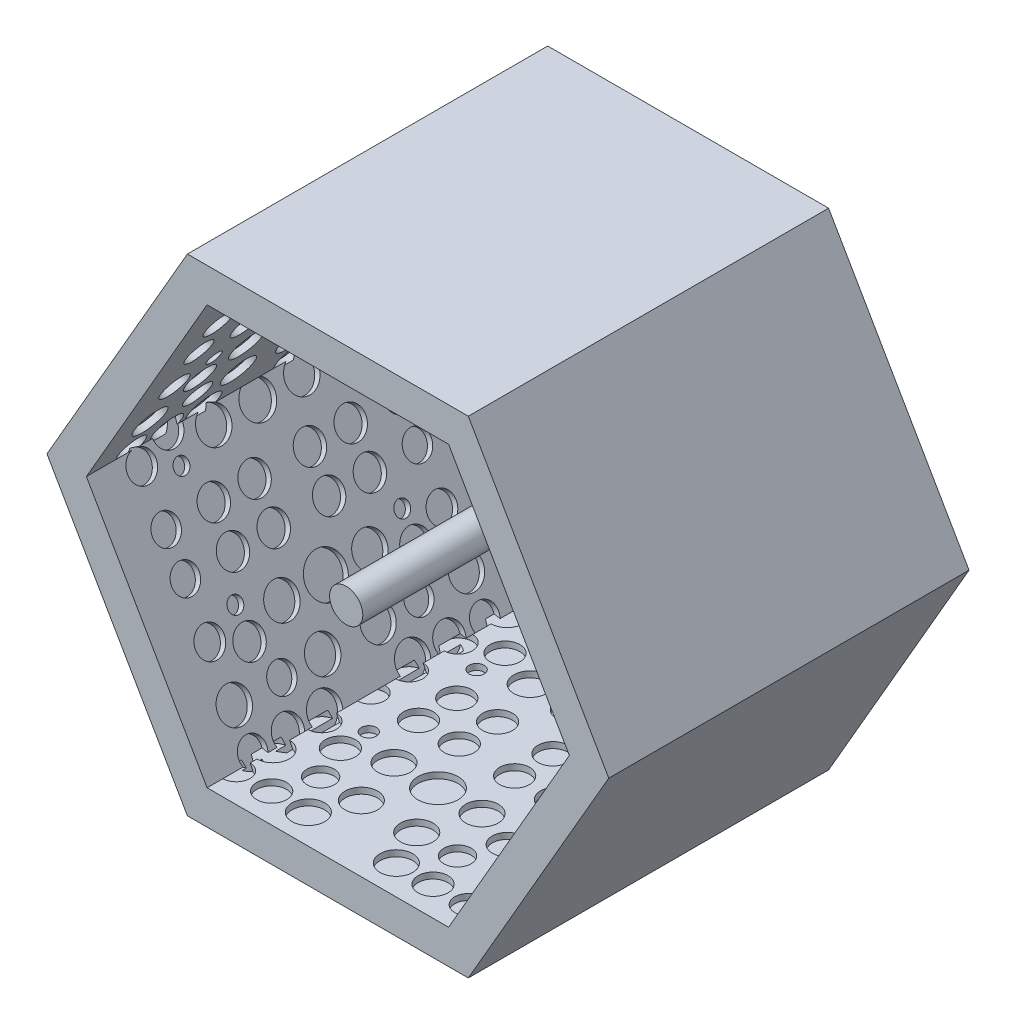
from build123d import *

# Parameters (mm, degrees)
SALIENTE_EXTRUIR2_DEPTH = 80
SALIENTE_EXTRUIR5_DEPTH = 510
CROQUIS4_R              = 151.648369314
SALIENTE_EXTRUIR6_DEPTH = 10
CROQUIS5_R              = 22.372806582
CROQUIS5_R_2            = 24.487952058
CROQUIS5_R_3            = 26.714129518
CROQUIS5_R_4            = 23.241975024
CROQUIS5_R_5            = 22.261774598
CROQUIS5_R_6            = 12.376864333
CROQUIS5_R_7            = 27.723252664
CROQUIS5_R_8            = 32.922117698
CORTAR_EXTRUIR1_DEPTH   = 10
CROQUIS7_R              = 22.372806582
CROQUIS7_R_2            = 24.487952058
CROQUIS7_R_3            = 26.714129518
CROQUIS7_R_4            = 23.241975024
CROQUIS7_R_5            = 22.261774598
CROQUIS7_R_6            = 12.376864333
CROQUIS7_R_7            = 27.723252664
CROQUIS7_R_8            = 32.922117698
CORTAR_EXTRUIR3_DEPTH   = 10
CROQUIS8_R              = 22.372806582
CROQUIS8_R_2            = 24.487952058
CROQUIS8_R_3            = 23.241975024
CROQUIS8_R_4            = 12.376864333
CROQUIS8_R_5            = 26.714129518
CROQUIS8_R_6            = 22.261774598
CROQUIS8_R_7            = 27.723252664
CROQUIS8_R_8            = 32.922117698
CORTAR_EXTRUIR4_DEPTH   = 10
CROQUIS9_R              = 22.372806582
CROQUIS9_R_2            = 24.487952058
CROQUIS9_R_3            = 23.241975024
CROQUIS9_R_4            = 12.376864333
CROQUIS9_R_5            = 26.714129518
CROQUIS9_R_6            = 22.261774598
CROQUIS9_R_7            = 27.723252664
CROQUIS9_R_8            = 32.922117698
CORTAR_EXTRUIR5_DEPTH   = 10
CROQUIS10_R             = 22.372806582
CROQUIS10_R_2           = 24.487952058
CROQUIS10_R_3           = 26.714129518
CROQUIS10_R_4           = 23.241975024
CROQUIS10_R_5           = 22.261774598
CROQUIS10_R_6           = 12.376864333
CROQUIS10_R_7           = 27.723252664
CROQUIS10_R_8           = 32.922117698
CORTAR_EXTRUIR6_DEPTH   = 10
CROQUIS11_R             = 22.372806582
CROQUIS11_R_2           = 24.487952058
CROQUIS11_R_3           = 26.714129518
CROQUIS11_R_4           = 23.241975024
CROQUIS11_R_5           = 22.261774598
CROQUIS11_R_6           = 12.376864333
CROQUIS11_R_7           = 27.723252664
CROQUIS11_R_8           = 32.922117698
CORTAR_EXTRUIR7_DEPTH   = 10
CROQUIS12_R             = 27.223768959
SALIENTE_EXTRUIR7_DEPTH = 470
CROQUIS13_R             = 241.497770317
SALIENTE_EXTRUIR8_DEPTH = 20


with BuildPart() as part:
    # Croquis1 → Saliente-Extruir2 (new body)
    with BuildSketch(Plane.XY):
        Polygon((460, 0), (230, 398.371685741), (-230, 398.371685741), (-460, 0), (-230, -398.371685741), (230, -398.371685741), align=None)
    extrude(amount=SALIENTE_EXTRUIR2_DEPTH)

    # Croquis3 → Saliente-Extruir5 (add)
    with BuildSketch(Plane.XY.offset(80)):
        Polygon((460, 0), (230, 398.371685741), (-230, 398.371685741), (-460, 0), (-230, -398.371685741), (230, -398.371685741), align=None)
        Polygon((395.452486161, 0), (197.726243081, 342.471899006), (-197.726243081, 342.471899006), (-395.452486161, 0), (-197.726243081, -342.471899006), (197.726243081, -342.471899006), align=None, mode=Mode.SUBTRACT)
    extrude(amount=SALIENTE_EXTRUIR5_DEPTH)

    # Croquis4 → Saliente-Extruir6 (add)
    with BuildSketch(Plane.XY.offset(80)):
        Circle(CROQUIS4_R)
    extrude(amount=SALIENTE_EXTRUIR6_DEPTH)

    # Croquis5 → Cortar-Extruir1 (cut)
    with BuildSketch(Plane.XZ.offset(-342.471899006)):
        with Locations((-190.032185774, 546.776665675)):
            Circle(CROQUIS5_R)
        with Locations((-132.151571818, 546.776665675)):
            Circle(CROQUIS5_R_2)
        with Locations((-72.044780403, 546.776665675)):
            Circle(CROQUIS5_R_3)
        with Locations((-45.330650885, 486.66987426)):
            Circle(CROQUIS5_R_3)
        with Locations((-190.032185774, 486.66987426)):
            Circle(CROQUIS5_R_3)
        with Locations((-190.032185774, 326.385097152)):
            Circle(CROQUIS5_R)
        with Locations((-112.11597468, 326.385097152)):
            Circle(CROQUIS5_R_2)
        with Locations((-45.330650885, 326.385097152)):
            Circle(CROQUIS5_R_2)
        with Locations((-190.032185774, 406.527485706)):
            Circle(CROQUIS5_R_4)
        with Locations((-136.603926738, 429.76946073)):
            Circle(CROQUIS5_R_2)
        with Locations((-112.11597468, 486.66987426)):
            Circle(CROQUIS5_R_5)
        with Locations((-136.603926738, 383.285510682)):
            Circle(CROQUIS5_R_6)
        with Locations((-72.044780403, 406.527485706)):
            Circle(CROQUIS5_R_3)
        with Locations((-72.044780403, 183.472514294)):
            Circle(CROQUIS5_R_3)
        with Locations((-136.603926738, 206.714489318)):
            Circle(CROQUIS5_R_6)
        with Locations((-112.11597468, 103.33012574)):
            Circle(CROQUIS5_R_5)
        with Locations((-136.603926738, 160.23053927)):
            Circle(CROQUIS5_R_2)
        with Locations((-190.032185774, 183.472514294)):
            Circle(CROQUIS5_R_4)
        with Locations((-45.330650885, 263.614902848)):
            Circle(CROQUIS5_R_2)
        with Locations((-112.11597468, 263.614902848)):
            Circle(CROQUIS5_R_2)
        with Locations((-190.032185774, 263.614902848)):
            Circle(CROQUIS5_R)
        with Locations((-190.032185774, 103.33012574)):
            Circle(CROQUIS5_R_3)
        with Locations((-45.330650885, 103.33012574)):
            Circle(CROQUIS5_R_3)
        with Locations((-72.044780403, 43.223334325)):
            Circle(CROQUIS5_R_3)
        with Locations((-132.151571818, 43.223334325)):
            Circle(CROQUIS5_R_2)
        with Locations((-190.032185774, 43.223334325)):
            Circle(CROQUIS5_R)
        with Locations((190.032185774, 43.223334325)):
            Circle(CROQUIS5_R)
        with Locations((132.151571818, 43.223334325)):
            Circle(CROQUIS5_R_2)
        with Locations((72.044780403, 43.223334325)):
            Circle(CROQUIS5_R_3)
        with Locations((45.330650885, 103.33012574)):
            Circle(CROQUIS5_R_3)
        with Locations((190.032185774, 103.33012574)):
            Circle(CROQUIS5_R_3)
        with Locations((190.032185774, 263.614902848)):
            Circle(CROQUIS5_R)
        with Locations((112.11597468, 263.614902848)):
            Circle(CROQUIS5_R_2)
        with Locations((45.330650885, 263.614902848)):
            Circle(CROQUIS5_R_2)
        with Locations((190.032185774, 183.472514294)):
            Circle(CROQUIS5_R_4)
        with Locations((136.603926738, 160.23053927)):
            Circle(CROQUIS5_R_2)
        with Locations((112.11597468, 103.33012574)):
            Circle(CROQUIS5_R_5)
        with Locations((136.603926738, 206.714489318)):
            Circle(CROQUIS5_R_6)
        with Locations((72.044780403, 183.472514294)):
            Circle(CROQUIS5_R_3)
        with Locations((72.044780403, 406.527485706)):
            Circle(CROQUIS5_R_3)
        with Locations((136.603926738, 383.285510682)):
            Circle(CROQUIS5_R_6)
        with Locations((112.11597468, 486.66987426)):
            Circle(CROQUIS5_R_5)
        with Locations((136.603926738, 429.76946073)):
            Circle(CROQUIS5_R_2)
        with Locations((190.032185774, 406.527485706)):
            Circle(CROQUIS5_R_4)
        with Locations((45.330650885, 326.385097152)):
            Circle(CROQUIS5_R_2)
        with Locations((112.11597468, 326.385097152)):
            Circle(CROQUIS5_R_2)
        with Locations((190.032185774, 326.385097152)):
            Circle(CROQUIS5_R)
        with Locations((190.032185774, 486.66987426)):
            Circle(CROQUIS5_R_3)
        with Locations((45.330650885, 486.66987426)):
            Circle(CROQUIS5_R_3)
        with Locations((72.044780403, 546.776665675)):
            Circle(CROQUIS5_R_3)
        with Locations((132.151571818, 546.776665675)):
            Circle(CROQUIS5_R_2)
        with Locations((190.032185774, 546.776665675)):
            Circle(CROQUIS5_R)
        with Locations((0, 406.527485706)):
            Circle(CROQUIS5_R_7)
        with Locations((0, 183.472514294)):
            Circle(CROQUIS5_R_8)
        with Locations((0, 546.776665675)):
            Circle(CROQUIS5_R_7)
    extrude(amount=-CORTAR_EXTRUIR1_DEPTH, mode=Mode.SUBTRACT)

    # Croquis7 → Cortar-Extruir3 (cut)
    with BuildSketch(Plane(origin=(296.589364621, 171.235949503, 0), x_dir=(0, 0, 1), z_dir=(-0.866025404, -0.5, 0))):
        with Locations((129.998680723, 189.418333487)):
            Circle(CROQUIS7_R)
        with Locations((187.879294678, 189.418333487)):
            Circle(CROQUIS7_R_2)
        with Locations((247.986086094, 189.418333487)):
            Circle(CROQUIS7_R_3)
        with Locations((274.700215612, 129.311542072)):
            Circle(CROQUIS7_R_3)
        with Locations((129.998680723, 129.311542072)):
            Circle(CROQUIS7_R_3)
        with Locations((129.998680723, -30.973235036)):
            Circle(CROQUIS7_R)
        with Locations((207.914891817, -30.973235036)):
            Circle(CROQUIS7_R_2)
        with Locations((274.700215612, -30.973235036)):
            Circle(CROQUIS7_R_2)
        with Locations((129.998680723, 49.169153518)):
            Circle(CROQUIS7_R_4)
        with Locations((183.426939759, 72.411128542)):
            Circle(CROQUIS7_R_2)
        with Locations((207.914891817, 129.311542072)):
            Circle(CROQUIS7_R_5)
        with Locations((183.426939759, 25.927178494)):
            Circle(CROQUIS7_R_6)
        with Locations((247.986086094, 49.169153518)):
            Circle(CROQUIS7_R_3)
        with Locations((247.986086094, -173.885817894)):
            Circle(CROQUIS7_R_3)
        with Locations((183.426939759, -150.643842871)):
            Circle(CROQUIS7_R_6)
        with Locations((183.426939759, -197.127792918)):
            Circle(CROQUIS7_R_2)
        with Locations((129.998680723, -173.885817894)):
            Circle(CROQUIS7_R_4)
        with Locations((274.700215612, -93.743429341)):
            Circle(CROQUIS7_R_2)
        with Locations((207.914891817, -93.743429341)):
            Circle(CROQUIS7_R_2)
        with Locations((129.998680723, -93.743429341)):
            Circle(CROQUIS7_R)
        with Locations((510.06305227, -93.743429341)):
            Circle(CROQUIS7_R)
        with Locations((432.146841176, -93.743429341)):
            Circle(CROQUIS7_R_2)
        with Locations((365.361517381, -93.743429341)):
            Circle(CROQUIS7_R_2)
        with Locations((510.06305227, -173.885817894)):
            Circle(CROQUIS7_R_4)
        with Locations((456.634793234, -197.127792918)):
            Circle(CROQUIS7_R_2)
        with Locations((456.634793234, -150.643842871)):
            Circle(CROQUIS7_R_6)
        with Locations((392.075646899, -173.885817894)):
            Circle(CROQUIS7_R_3)
        with Locations((392.075646899, 49.169153518)):
            Circle(CROQUIS7_R_3)
        with Locations((456.634793234, 25.927178494)):
            Circle(CROQUIS7_R_6)
        with Locations((432.146841176, 129.311542072)):
            Circle(CROQUIS7_R_5)
        with Locations((456.634793234, 72.411128542)):
            Circle(CROQUIS7_R_2)
        with Locations((510.06305227, 49.169153518)):
            Circle(CROQUIS7_R_4)
        with Locations((365.361517381, -30.973235036)):
            Circle(CROQUIS7_R_2)
        with Locations((432.146841176, -30.973235036)):
            Circle(CROQUIS7_R_2)
        with Locations((510.06305227, -30.973235036)):
            Circle(CROQUIS7_R)
        with Locations((510.06305227, 129.311542072)):
            Circle(CROQUIS7_R_3)
        with Locations((365.361517381, 129.311542072)):
            Circle(CROQUIS7_R_3)
        with Locations((392.075646899, 189.418333487)):
            Circle(CROQUIS7_R_3)
        with Locations((452.182438314, 189.418333487)):
            Circle(CROQUIS7_R_2)
        with Locations((510.06305227, 189.418333487)):
            Circle(CROQUIS7_R)
        with Locations((320.030866496, 49.169153518)):
            Circle(CROQUIS7_R_7)
        with Locations((320.030866496, -173.885817894)):
            Circle(CROQUIS7_R_8)
        with Locations((320.030866496, 189.418333487)):
            Circle(CROQUIS7_R_7)
    extrude(amount=-CORTAR_EXTRUIR3_DEPTH, mode=Mode.SUBTRACT)

    # Croquis8 → Cortar-Extruir4 (cut)
    with BuildSketch(Plane(origin=(-296.589364621, 171.235949503, 0), x_dir=(0, 0, -1), z_dir=(0.866025404, -0.5, 0))):
        with Locations((-521.340440791, 96.533218482)):
            Circle(CROQUIS8_R)
        with Locations((-443.424229697, 96.533218482)):
            Circle(CROQUIS8_R_2)
        with Locations((-376.638905902, 96.533218482)):
            Circle(CROQUIS8_R_2)
        with Locations((-521.340440791, 176.675607036)):
            Circle(CROQUIS8_R_3)
        with Locations((-467.912181755, 199.91758206)):
            Circle(CROQUIS8_R_2)
        with Locations((-467.912181755, 153.433632012)):
            Circle(CROQUIS8_R_4)
        with Locations((-403.35303542, 176.675607036)):
            Circle(CROQUIS8_R_5)
        with Locations((-403.35303542, -46.379364376)):
            Circle(CROQUIS8_R_5)
        with Locations((-467.912181755, -23.137389352)):
            Circle(CROQUIS8_R_4)
        with Locations((-443.424229697, -126.52175293)):
            Circle(CROQUIS8_R_6)
        with Locations((-467.912181755, -69.6213394)):
            Circle(CROQUIS8_R_2)
        with Locations((-521.340440791, -46.379364376)):
            Circle(CROQUIS8_R_3)
        with Locations((-376.638905902, 33.763024178)):
            Circle(CROQUIS8_R_2)
        with Locations((-443.424229697, 33.763024178)):
            Circle(CROQUIS8_R_2)
        with Locations((-521.340440791, 33.763024178)):
            Circle(CROQUIS8_R)
        with Locations((-521.340440791, -126.52175293)):
            Circle(CROQUIS8_R_5)
        with Locations((-376.638905902, -126.52175293)):
            Circle(CROQUIS8_R_5)
        with Locations((-403.35303542, -186.628544345)):
            Circle(CROQUIS8_R_5)
        with Locations((-463.459826836, -186.628544345)):
            Circle(CROQUIS8_R_2)
        with Locations((-521.340440791, -186.628544345)):
            Circle(CROQUIS8_R)
        with Locations((-141.276069244, -186.628544345)):
            Circle(CROQUIS8_R)
        with Locations((-199.1566832, -186.628544345)):
            Circle(CROQUIS8_R_2)
        with Locations((-259.263474615, -186.628544345)):
            Circle(CROQUIS8_R_5)
        with Locations((-285.977604133, -126.52175293)):
            Circle(CROQUIS8_R_5)
        with Locations((-141.276069244, -126.52175293)):
            Circle(CROQUIS8_R_5)
        with Locations((-141.276069244, 33.763024178)):
            Circle(CROQUIS8_R)
        with Locations((-219.192280338, 33.763024178)):
            Circle(CROQUIS8_R_2)
        with Locations((-285.977604133, 33.763024178)):
            Circle(CROQUIS8_R_2)
        with Locations((-141.276069244, -46.379364376)):
            Circle(CROQUIS8_R_3)
        with Locations((-194.70432828, -69.6213394)):
            Circle(CROQUIS8_R_2)
        with Locations((-219.192280338, -126.52175293)):
            Circle(CROQUIS8_R_6)
        with Locations((-194.70432828, -23.137389352)):
            Circle(CROQUIS8_R_4)
        with Locations((-259.263474615, -46.379364376)):
            Circle(CROQUIS8_R_5)
        with Locations((-259.263474615, 176.675607036)):
            Circle(CROQUIS8_R_5)
        with Locations((-194.70432828, 153.433632012)):
            Circle(CROQUIS8_R_4)
        with Locations((-194.70432828, 199.91758206)):
            Circle(CROQUIS8_R_2)
        with Locations((-141.276069244, 176.675607036)):
            Circle(CROQUIS8_R_3)
        with Locations((-285.977604133, 96.533218482)):
            Circle(CROQUIS8_R_2)
        with Locations((-219.192280338, 96.533218482)):
            Circle(CROQUIS8_R_2)
        with Locations((-141.276069244, 96.533218482)):
            Circle(CROQUIS8_R)
        with Locations((-331.308255018, 176.675607036)):
            Circle(CROQUIS8_R_7)
        with Locations((-331.308255018, -46.379364376)):
            Circle(CROQUIS8_R_8)
    extrude(amount=-CORTAR_EXTRUIR4_DEPTH, mode=Mode.SUBTRACT)

    # Croquis9 → Cortar-Extruir5 (cut)
    with BuildSketch(Plane(origin=(-296.589364621, -171.235949503, 0), x_dir=(0, 0, -1), z_dir=(0.866025404, 0.5, 0))):
        with Locations((-510.625554274, 94.984817921)):
            Circle(CROQUIS9_R)
        with Locations((-432.70934318, 94.984817921)):
            Circle(CROQUIS9_R_2)
        with Locations((-365.924019385, 94.984817921)):
            Circle(CROQUIS9_R_2)
        with Locations((-510.625554274, 175.127206475)):
            Circle(CROQUIS9_R_3)
        with Locations((-457.197295238, 198.369181498)):
            Circle(CROQUIS9_R_2)
        with Locations((-457.197295238, 151.885231451)):
            Circle(CROQUIS9_R_4)
        with Locations((-392.638148903, 175.127206475)):
            Circle(CROQUIS9_R_5)
        with Locations((-392.638148903, -47.927764938)):
            Circle(CROQUIS9_R_5)
        with Locations((-457.197295238, -24.685789914)):
            Circle(CROQUIS9_R_4)
        with Locations((-432.70934318, -128.070153491)):
            Circle(CROQUIS9_R_6)
        with Locations((-457.197295238, -71.169739961)):
            Circle(CROQUIS9_R_2)
        with Locations((-510.625554274, -47.927764938)):
            Circle(CROQUIS9_R_3)
        with Locations((-365.924019385, 32.214623616)):
            Circle(CROQUIS9_R_2)
        with Locations((-432.70934318, 32.214623616)):
            Circle(CROQUIS9_R_2)
        with Locations((-510.625554274, 32.214623616)):
            Circle(CROQUIS9_R)
        with Locations((-510.625554274, -128.070153491)):
            Circle(CROQUIS9_R_5)
        with Locations((-365.924019385, -128.070153491)):
            Circle(CROQUIS9_R_5)
        with Locations((-392.638148903, -188.176944907)):
            Circle(CROQUIS9_R_5)
        with Locations((-452.744940318, -188.176944907)):
            Circle(CROQUIS9_R_2)
        with Locations((-510.625554274, -188.176944907)):
            Circle(CROQUIS9_R)
        with Locations((-130.561182727, -188.176944907)):
            Circle(CROQUIS9_R)
        with Locations((-188.441796682, -188.176944907)):
            Circle(CROQUIS9_R_2)
        with Locations((-248.548588098, -188.176944907)):
            Circle(CROQUIS9_R_5)
        with Locations((-275.262717615, -128.070153491)):
            Circle(CROQUIS9_R_5)
        with Locations((-130.561182727, -128.070153491)):
            Circle(CROQUIS9_R_5)
        with Locations((-130.561182727, 32.214623616)):
            Circle(CROQUIS9_R)
        with Locations((-208.477393821, 32.214623616)):
            Circle(CROQUIS9_R_2)
        with Locations((-275.262717615, 32.214623616)):
            Circle(CROQUIS9_R_2)
        with Locations((-130.561182727, -47.927764938)):
            Circle(CROQUIS9_R_3)
        with Locations((-183.989441762, -71.169739961)):
            Circle(CROQUIS9_R_2)
        with Locations((-208.477393821, -128.070153491)):
            Circle(CROQUIS9_R_6)
        with Locations((-183.989441762, -24.685789914)):
            Circle(CROQUIS9_R_4)
        with Locations((-248.548588098, -47.927764938)):
            Circle(CROQUIS9_R_5)
        with Locations((-248.548588098, 175.127206475)):
            Circle(CROQUIS9_R_5)
        with Locations((-183.989441762, 151.885231451)):
            Circle(CROQUIS9_R_4)
        with Locations((-183.989441762, 198.369181498)):
            Circle(CROQUIS9_R_2)
        with Locations((-130.561182727, 175.127206475)):
            Circle(CROQUIS9_R_3)
        with Locations((-275.262717615, 94.984817921)):
            Circle(CROQUIS9_R_2)
        with Locations((-208.477393821, 94.984817921)):
            Circle(CROQUIS9_R_2)
        with Locations((-130.561182727, 94.984817921)):
            Circle(CROQUIS9_R)
        with Locations((-320.5933685, 175.127206475)):
            Circle(CROQUIS9_R_7)
        with Locations((-320.5933685, -47.927764938)):
            Circle(CROQUIS9_R_8)
    extrude(amount=-CORTAR_EXTRUIR5_DEPTH, mode=Mode.SUBTRACT)

    # Croquis10 → Cortar-Extruir6 (cut)
    with BuildSketch(Plane(origin=(0, -342.471899006, 0), x_dir=(1, 0, 0), z_dir=(0, 1, 0))):
        with Locations((-198.120445462, -38.2313426)):
            Circle(CROQUIS10_R)
        with Locations((-140.239831507, -38.2313426)):
            Circle(CROQUIS10_R_2)
        with Locations((-80.133040091, -38.2313426)):
            Circle(CROQUIS10_R_3)
        with Locations((-53.418910573, -98.338134015)):
            Circle(CROQUIS10_R_3)
        with Locations((-198.120445462, -98.338134015)):
            Circle(CROQUIS10_R_3)
        with Locations((-198.120445462, -258.622911123)):
            Circle(CROQUIS10_R)
        with Locations((-120.204234368, -258.622911123)):
            Circle(CROQUIS10_R_2)
        with Locations((-53.418910573, -258.622911123)):
            Circle(CROQUIS10_R_2)
        with Locations((-198.120445462, -178.480522569)):
            Circle(CROQUIS10_R_4)
        with Locations((-144.692186426, -155.238547545)):
            Circle(CROQUIS10_R_2)
        with Locations((-120.204234368, -98.338134015)):
            Circle(CROQUIS10_R_5)
        with Locations((-144.692186426, -201.722497593)):
            Circle(CROQUIS10_R_6)
        with Locations((-80.133040091, -178.480522569)):
            Circle(CROQUIS10_R_3)
        with Locations((-80.133040091, -401.535493982)):
            Circle(CROQUIS10_R_3)
        with Locations((-144.692186426, -378.293518958)):
            Circle(CROQUIS10_R_6)
        with Locations((-120.204234368, -481.677882535)):
            Circle(CROQUIS10_R_5)
        with Locations((-144.692186426, -424.777469005)):
            Circle(CROQUIS10_R_2)
        with Locations((-198.120445462, -401.535493982)):
            Circle(CROQUIS10_R_4)
        with Locations((-53.418910573, -321.393105428)):
            Circle(CROQUIS10_R_2)
        with Locations((-120.204234368, -321.393105428)):
            Circle(CROQUIS10_R_2)
        with Locations((-198.120445462, -321.393105428)):
            Circle(CROQUIS10_R)
        with Locations((-198.120445462, -481.677882535)):
            Circle(CROQUIS10_R_3)
        with Locations((-53.418910573, -481.677882535)):
            Circle(CROQUIS10_R_3)
        with Locations((-80.133040091, -541.784673951)):
            Circle(CROQUIS10_R_3)
        with Locations((-140.239831507, -541.784673951)):
            Circle(CROQUIS10_R_2)
        with Locations((-198.120445462, -541.784673951)):
            Circle(CROQUIS10_R)
        with Locations((181.943926085, -541.784673951)):
            Circle(CROQUIS10_R)
        with Locations((124.063312129, -541.784673951)):
            Circle(CROQUIS10_R_2)
        with Locations((63.956520714, -541.784673951)):
            Circle(CROQUIS10_R_3)
        with Locations((37.242391196, -481.677882535)):
            Circle(CROQUIS10_R_3)
        with Locations((181.943926085, -481.677882535)):
            Circle(CROQUIS10_R_3)
        with Locations((181.943926085, -321.393105428)):
            Circle(CROQUIS10_R)
        with Locations((104.027714991, -321.393105428)):
            Circle(CROQUIS10_R_2)
        with Locations((37.242391196, -321.393105428)):
            Circle(CROQUIS10_R_2)
        with Locations((181.943926085, -401.535493982)):
            Circle(CROQUIS10_R_4)
        with Locations((128.515667049, -424.777469005)):
            Circle(CROQUIS10_R_2)
        with Locations((104.027714991, -481.677882535)):
            Circle(CROQUIS10_R_5)
        with Locations((128.515667049, -378.293518958)):
            Circle(CROQUIS10_R_6)
        with Locations((63.956520714, -401.535493982)):
            Circle(CROQUIS10_R_3)
        with Locations((63.956520714, -178.480522569)):
            Circle(CROQUIS10_R_3)
        with Locations((128.515667049, -201.722497593)):
            Circle(CROQUIS10_R_6)
        with Locations((104.027714991, -98.338134015)):
            Circle(CROQUIS10_R_5)
        with Locations((128.515667049, -155.238547545)):
            Circle(CROQUIS10_R_2)
        with Locations((181.943926085, -178.480522569)):
            Circle(CROQUIS10_R_4)
        with Locations((37.242391196, -258.622911123)):
            Circle(CROQUIS10_R_2)
        with Locations((104.027714991, -258.622911123)):
            Circle(CROQUIS10_R_2)
        with Locations((181.943926085, -258.622911123)):
            Circle(CROQUIS10_R)
        with Locations((181.943926085, -98.338134015)):
            Circle(CROQUIS10_R_3)
        with Locations((37.242391196, -98.338134015)):
            Circle(CROQUIS10_R_3)
        with Locations((63.956520714, -38.2313426)):
            Circle(CROQUIS10_R_3)
        with Locations((124.063312129, -38.2313426)):
            Circle(CROQUIS10_R_2)
        with Locations((181.943926085, -38.2313426)):
            Circle(CROQUIS10_R)
        with Locations((-8.088259689, -178.480522569)):
            Circle(CROQUIS10_R_7)
        with Locations((-8.088259689, -401.535493982)):
            Circle(CROQUIS10_R_8)
        with Locations((-8.088259689, -38.2313426)):
            Circle(CROQUIS10_R_7)
    extrude(amount=-CORTAR_EXTRUIR6_DEPTH, mode=Mode.SUBTRACT)

    # Croquis11 → Cortar-Extruir7 (cut)
    with BuildSketch(Plane(origin=(296.589364621, -171.235949503, 0), x_dir=(0, 0, 1), z_dir=(-0.866025404, 0.5, 0))):
        with Locations((131.799823438, 182.359179349)):
            Circle(CROQUIS11_R)
        with Locations((189.680437394, 182.359179349)):
            Circle(CROQUIS11_R_2)
        with Locations((249.787228809, 182.359179349)):
            Circle(CROQUIS11_R_3)
        with Locations((276.501358327, 122.252387933)):
            Circle(CROQUIS11_R_3)
        with Locations((131.799823438, 122.252387933)):
            Circle(CROQUIS11_R_3)
        with Locations((131.799823438, -38.032389174)):
            Circle(CROQUIS11_R)
        with Locations((209.716034532, -38.032389174)):
            Circle(CROQUIS11_R_2)
        with Locations((276.501358327, -38.032389174)):
            Circle(CROQUIS11_R_2)
        with Locations((131.799823438, 42.10999938)):
            Circle(CROQUIS11_R_4)
        with Locations((185.228082474, 65.351974403)):
            Circle(CROQUIS11_R_2)
        with Locations((209.716034532, 122.252387933)):
            Circle(CROQUIS11_R_5)
        with Locations((185.228082474, 18.868024356)):
            Circle(CROQUIS11_R_6)
        with Locations((249.787228809, 42.10999938)):
            Circle(CROQUIS11_R_3)
        with Locations((249.787228809, -180.944972033)):
            Circle(CROQUIS11_R_3)
        with Locations((185.228082474, -157.702997009)):
            Circle(CROQUIS11_R_6)
        with Locations((185.228082474, -204.186947057)):
            Circle(CROQUIS11_R_2)
        with Locations((131.799823438, -180.944972033)):
            Circle(CROQUIS11_R_4)
        with Locations((276.501358327, -100.802583479)):
            Circle(CROQUIS11_R_2)
        with Locations((209.716034532, -100.802583479)):
            Circle(CROQUIS11_R_2)
        with Locations((131.799823438, -100.802583479)):
            Circle(CROQUIS11_R)
        with Locations((511.864194985, -100.802583479)):
            Circle(CROQUIS11_R)
        with Locations((433.947983891, -100.802583479)):
            Circle(CROQUIS11_R_2)
        with Locations((367.162660096, -100.802583479)):
            Circle(CROQUIS11_R_2)
        with Locations((511.864194985, -180.944972033)):
            Circle(CROQUIS11_R_4)
        with Locations((458.435935949, -204.186947057)):
            Circle(CROQUIS11_R_2)
        with Locations((458.435935949, -157.702997009)):
            Circle(CROQUIS11_R_6)
        with Locations((393.876789614, -180.944972033)):
            Circle(CROQUIS11_R_3)
        with Locations((393.876789614, 42.10999938)):
            Circle(CROQUIS11_R_3)
        with Locations((458.435935949, 18.868024356)):
            Circle(CROQUIS11_R_6)
        with Locations((433.947983891, 122.252387933)):
            Circle(CROQUIS11_R_5)
        with Locations((458.435935949, 65.351974403)):
            Circle(CROQUIS11_R_2)
        with Locations((511.864194985, 42.10999938)):
            Circle(CROQUIS11_R_4)
        with Locations((367.162660096, -38.032389174)):
            Circle(CROQUIS11_R_2)
        with Locations((433.947983891, -38.032389174)):
            Circle(CROQUIS11_R_2)
        with Locations((511.864194985, -38.032389174)):
            Circle(CROQUIS11_R)
        with Locations((511.864194985, 122.252387933)):
            Circle(CROQUIS11_R_3)
        with Locations((367.162660096, 122.252387933)):
            Circle(CROQUIS11_R_3)
        with Locations((393.876789614, 182.359179349)):
            Circle(CROQUIS11_R_3)
        with Locations((453.98358103, 182.359179349)):
            Circle(CROQUIS11_R_2)
        with Locations((511.864194985, 182.359179349)):
            Circle(CROQUIS11_R)
        with Locations((321.832009212, 42.10999938)):
            Circle(CROQUIS11_R_7)
        with Locations((321.832009212, -180.944972033)):
            Circle(CROQUIS11_R_8)
        with Locations((321.832009212, 182.359179349)):
            Circle(CROQUIS11_R_7)
    extrude(amount=-CORTAR_EXTRUIR7_DEPTH, mode=Mode.SUBTRACT)

    # Croquis12 → Saliente-Extruir7 (add)
    with BuildSketch(Plane.XY.offset(90)):
        Circle(CROQUIS12_R)
    extrude(amount=SALIENTE_EXTRUIR7_DEPTH)

    # Croquis13 → Saliente-Extruir8 (add)
    with BuildSketch(Plane(origin=(0, 0, 0), x_dir=(-1, 0, 0), z_dir=(0, 0, -1))):
        Circle(CROQUIS13_R)
    extrude(amount=SALIENTE_EXTRUIR8_DEPTH)


solid = part.part
